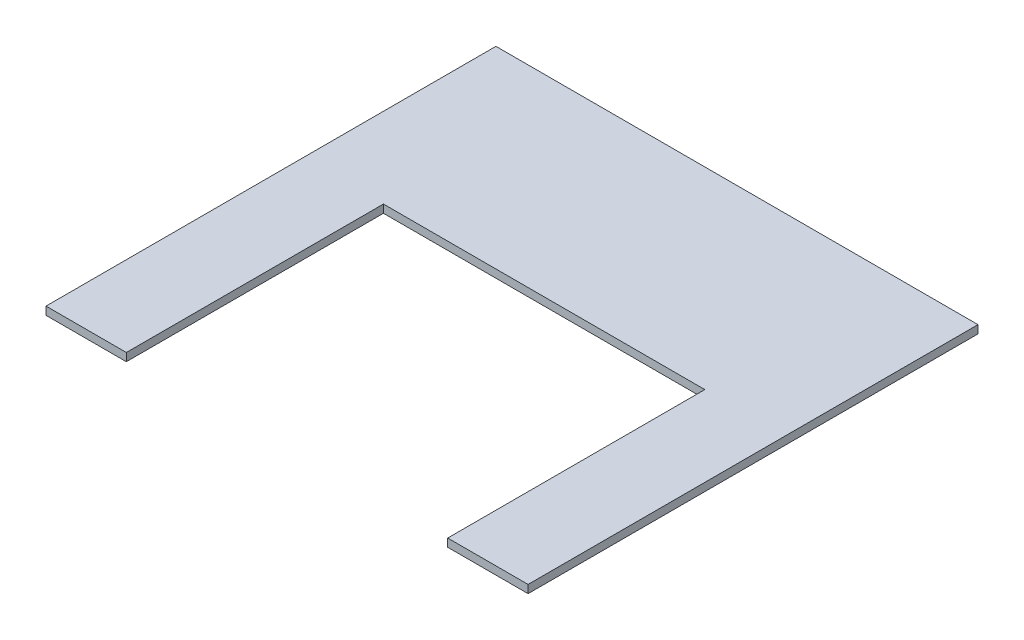
from build123d import *

# Parameters (mm, degrees)
SKETCH1_W           = 381
SKETCH1_H           = 429.26
BOSS_EXTRUDE1_DEPTH = 6.35
SKETCH2_W           = 254
SKETCH2_H           = 203.2
CUT_EXTRUDE1_DEPTH  = 6.35
SKETCH3_W           = 381
SKETCH3_H           = 73.66
CUT_EXTRUDE2_DEPTH  = 6.35
SKETCH4_W           = 254
SKETCH4_H           = 6.35
CUT_EXTRUDE3_DEPTH  = 73.66


with BuildPart() as part:
    # Sketch1 → Boss-Extrude1 (new body)
    with BuildSketch(Plane(origin=(0, 0, 0), x_dir=(1, 0, 0), z_dir=(0, 1, 0))):
        with Locations((190.5, 214.63)):
            Rectangle(SKETCH1_W, SKETCH1_H)
    extrude(amount=BOSS_EXTRUDE1_DEPTH)

    # Sketch2 → Cut-Extrude1 (cut)
    with BuildSketch(Plane(origin=(0, 6.35, 0), x_dir=(1, 0, 0), z_dir=(0, 1, 0))):
        with Locations((190.5, 101.6)):
            Rectangle(SKETCH2_W, SKETCH2_H)
    extrude(amount=-CUT_EXTRUDE1_DEPTH, mode=Mode.SUBTRACT)

    # Sketch3 → Cut-Extrude2 (cut)
    with BuildSketch(Plane(origin=(0, 6.35, 0), x_dir=(1, 0, 0), z_dir=(0, 1, 0))):
        with Locations((190.5, 36.83)):
            Rectangle(SKETCH3_W, SKETCH3_H)
    extrude(amount=-CUT_EXTRUDE2_DEPTH, mode=Mode.SUBTRACT)

    # Sketch4 → Cut-Extrude3 (cut)
    with BuildSketch(Plane.XY.offset(-203.2)):
        with Locations((190.5, 3.175)):
            Rectangle(SKETCH4_W, SKETCH4_H)
    extrude(amount=-CUT_EXTRUDE3_DEPTH, mode=Mode.SUBTRACT)


solid = part.part
